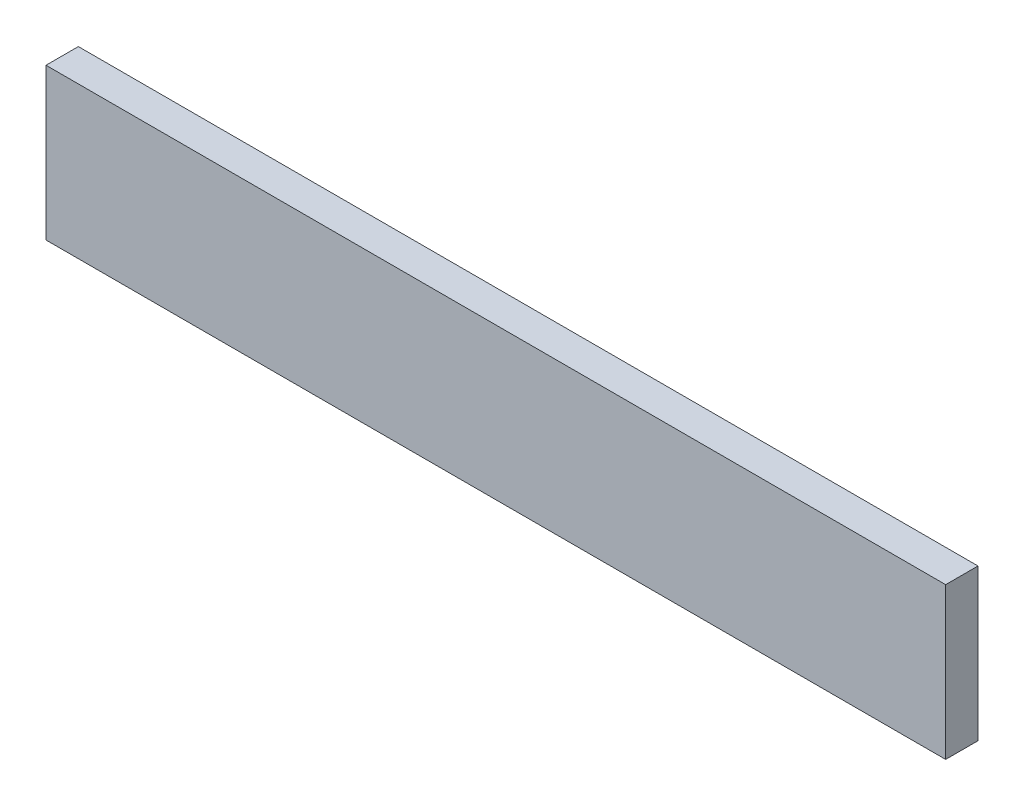
from build123d import *

# Parameters (mm, degrees)
ESQUISSE1_W        = 27.80602061
ESQUISSE1_H        = 4.678636079
BOSS_EXTRU_1_DEPTH = 1


with BuildPart() as part:
    # Esquisse1 → Boss.-Extru.1 (new body)
    with BuildSketch(Plane.XY):
        with Locations((-5.178480401, 24.673800799)):
            Rectangle(ESQUISSE1_W, ESQUISSE1_H)
    extrude(amount=BOSS_EXTRU_1_DEPTH)


solid = part.part
